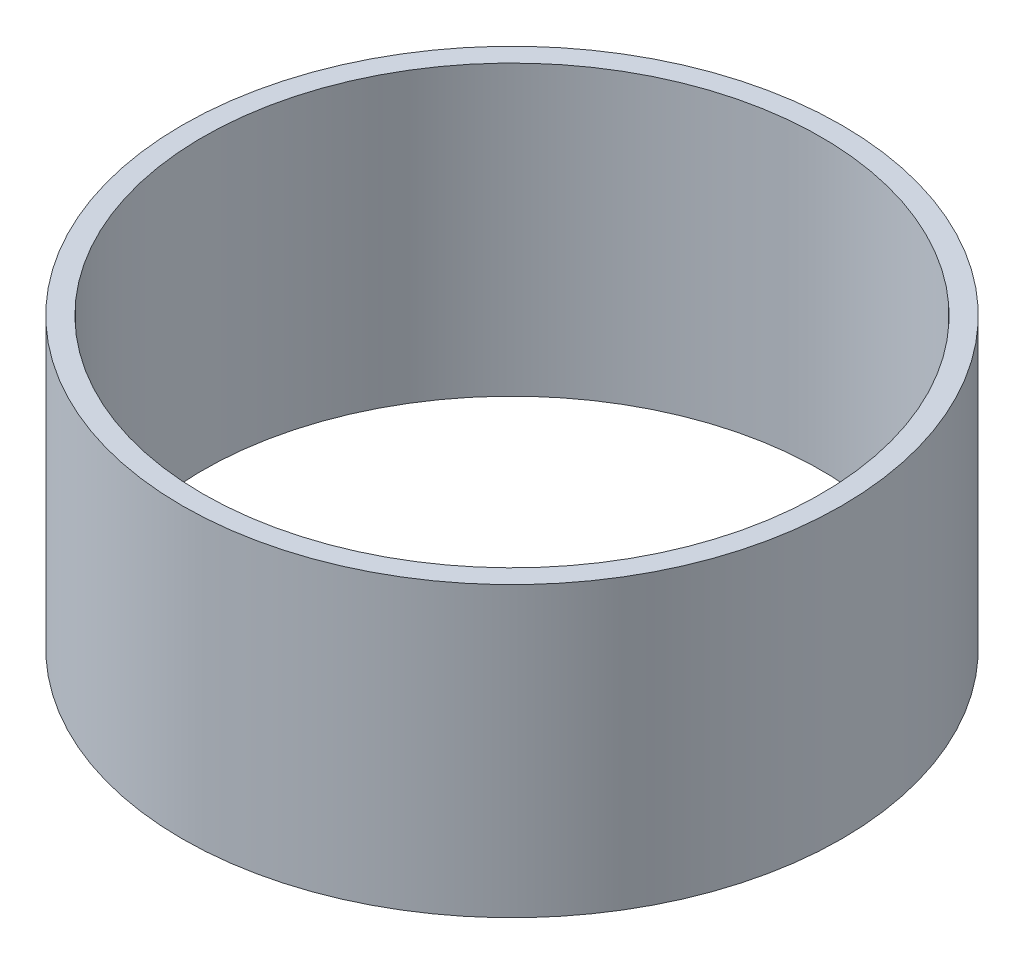
from build123d import *

# Parameters (mm, degrees)
SKETCH1_R           = 32
SKETCH1_R_2         = 30
EXTRUDE_THIN1_DEPTH = 28


with BuildPart() as part:
    # Sketch1 → Extrude-Thin1 (new body)
    with BuildSketch(Plane(origin=(0, 0, 0), x_dir=(1, 0, 0), z_dir=(0, 1, 0))):
        Circle(SKETCH1_R)
        Circle(SKETCH1_R_2, mode=Mode.SUBTRACT)
    extrude(amount=EXTRUDE_THIN1_DEPTH)


solid = part.part
